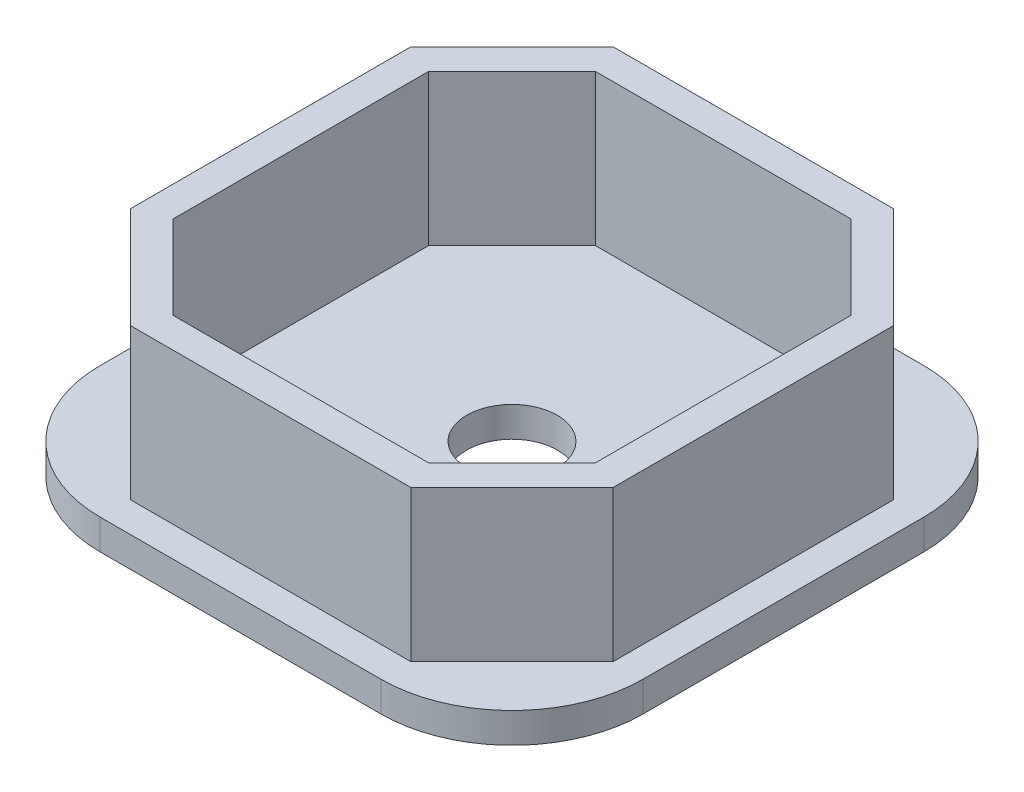
from build123d import *

# Parameters (mm, degrees)
SKETCH1_R           = 1.5
BOSS_EXTRUDE1_DEPTH = 1
BOSS_EXTRUDE2_DEPTH = 5


with BuildPart() as part:
    # Sketch1 → Boss-Extrude1 (new body)
    with BuildSketch(Plane(origin=(0, 0, 0), x_dir=(1, 0, 0), z_dir=(0, 1, 0))):
        with BuildLine():
            Line((-4.65, -9), (4.65, -9))
            ThreePointArc((4.65, -9), (7.725914498, -7.725914498), (9, -4.65))
            Line((9, -4.65), (9, 4.65))
            ThreePointArc((9, 4.65), (7.725914498, 7.725914498), (4.65, 9))
            Line((4.65, 9), (-4.65, 9))
            ThreePointArc((-4.65, 9), (-7.725914498, 7.725914498), (-9, 4.65))
            Line((-9, 4.65), (-9, -4.65))
            ThreePointArc((-9, -4.65), (-7.725914498, -7.725914498), (-4.65, -9))
        make_face()
        Circle(SKETCH1_R, mode=Mode.SUBTRACT)
    extrude(amount=BOSS_EXTRUDE1_DEPTH)

    # Sketch2 → Boss-Extrude2 (add)
    with BuildSketch(Plane(origin=(0, 1, 0), x_dir=(1, 0, 0), z_dir=(0, 1, 0))):
        Polygon((-8, 4.65), (-4.65, 8), (4.65, 8), (8, 4.65), (8, -4.65), (4.65, -8), (-4.65, -8), (-8, -4.65), align=None)
        Polygon((-7, 4.235786438), (-4.235786438, 7), (4.235786438, 7), (7, 4.235786438), (7, -4.235786438), (4.235786438, -7), (-4.235786438, -7), (-7, -4.235786438), align=None, mode=Mode.SUBTRACT)
    extrude(amount=BOSS_EXTRUDE2_DEPTH)


solid = part.part
